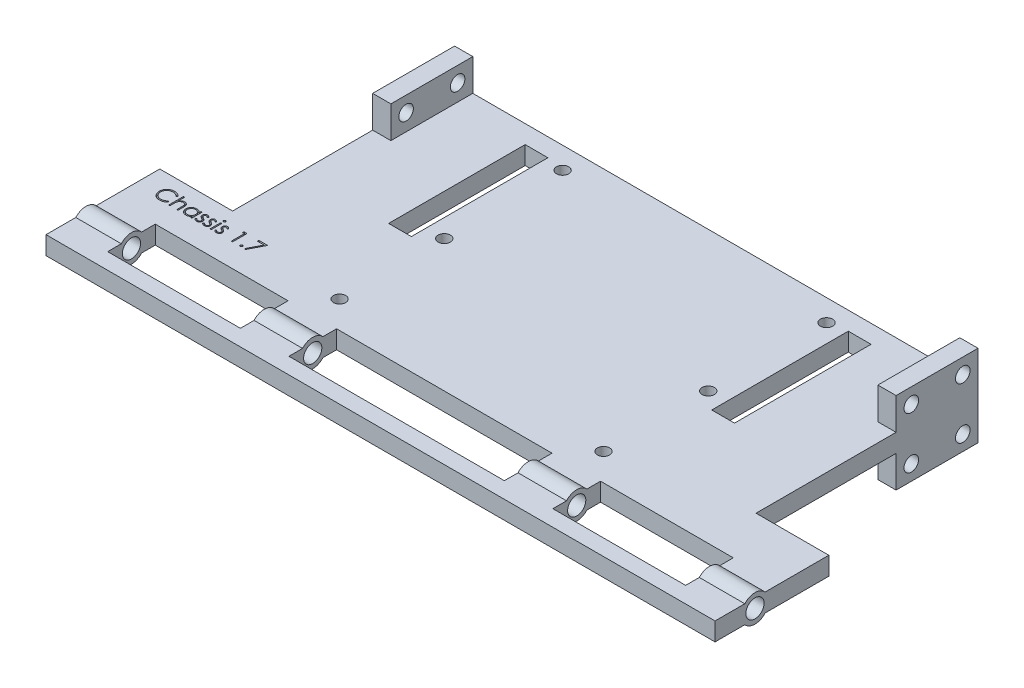
from build123d import *

# Parameters (mm, degrees)
SKETCH1_R           = 1.35
SKETCH1_W           = 5
SKETCH1_H           = 30
BASE_CHASSIS_DEPTH  = 2
SKETCH14_W          = 0.284935898
SKETCH14_H          = 2.320192307
TEXT_2_DEPTH        = 0.5
SKETCH7_W           = 18
SKETCH7_H           = 18
SKETCH7_R           = 1.6
MOUNT_HOLES_DEPTH   = 4
SKETCH8_R           = 3
SHAFT_EXTRUDE_DEPTH = 147
SKETCH20_R          = 2
SHAFT_CUT_DEPTH     = 148.0000001
SCREW_START         = -12
SCREW_HOLE_DEPTH    = 20


with BuildPart() as part:
    # Sketch1 → Base Chassis (new body, symmetric)
    with BuildSketch(Plane(origin=(0, 0, 0), x_dir=(1, 0, 0), z_dir=(0, 1, 0))):
        Polygon((0, 0), (115, 0), (115, -48.77649394), (131, -48.77649394), (131, -73.77649394), (-16, -73.77649394), (-16, -48.77649394), (0, -48.77649394), align=None)
        with Locations((28.5, -30.77649394)):
            Circle(SKETCH1_R, mode=Mode.SUBTRACT)
        with Locations((28.5, -53.77649394)):
            Circle(SKETCH1_R, mode=Mode.SUBTRACT)
        with Locations((86.5, -30.77649394)):
            Circle(SKETCH1_R, mode=Mode.SUBTRACT)
        with Locations((86.5, -53.77649394)):
            Circle(SKETCH1_R, mode=Mode.SUBTRACT)
        with Locations((86.5, -4.77649394)):
            Circle(SKETCH1_R, mode=Mode.SUBTRACT)
        with Locations((28.5, -4.77649394)):
            Circle(SKETCH1_R, mode=Mode.SUBTRACT)
        with Locations((22, -19)):
            Rectangle(SKETCH1_W, SKETCH1_H, mode=Mode.SUBTRACT)
        with Locations((93, -19)):
            Rectangle(SKETCH1_W, SKETCH1_H, mode=Mode.SUBTRACT)
    extrude(amount=BASE_CHASSIS_DEPTH, both=True)

    # Sketch14 → Text 2 (cut)
    with BuildSketch(Plane(origin=(0, 2, 0), x_dir=(1, 0, 0), z_dir=(0, 1, 0))):
        with BuildLine():
            Line((-8.734459633, -52.056852352), (-8.983778544, -52.24765764))
            add(Edge.make_bspline(
                [(-8.983778544, -52.24765764), (-9.001563885, -52.226461368), (-9.036894783, -52.184354594), (-9.093735631, -52.125227436), (-9.15297355, -52.06983252), (-9.214585896, -52.017905958), (-9.279681669, -51.971263606), (-9.346683965, -51.92747482), (-9.41671362, -51.8882248), (-9.513552693, -51.840633377), (-9.640233241, -51.790970794), (-9.799704274, -51.749330005), (-9.966175056, -51.722822225), (-10.079747165, -51.719951261), (-10.137514521, -51.718490974)],
                knots=[0, 0, 0, 0, 8.299e-05, 0.000164861, 0.000245858, 0.000326233, 0.000406381, 0.000485944, 0.000566254, 0.000647036, 0.000809554, 0.000973391, 0.001140702, 0.001313896, 0.001313896, 0.001313896, 0.001313896], degree=3))
            add(Edge.make_bspline(
                [(-10.137514521, -51.718490974), (-10.169340086, -51.718857425), (-10.232695843, -51.719586928), (-10.326719815, -51.72921092), (-10.418988083, -51.742737517), (-10.509440628, -51.762808346), (-10.597962311, -51.788183508), (-10.685131848, -51.818505134), (-10.769687177, -51.856019881), (-10.852798008, -51.897483803), (-10.932426292, -51.94431727), (-11.007769085, -51.995401525), (-11.078551599, -52.05016492), (-11.144829826, -52.108812709), (-11.206671522, -52.171080773), (-11.263628582, -52.237632712), (-11.315503919, -52.308255755), (-11.363325792, -52.382018632), (-11.406154485, -52.458706486), (-11.442013733, -52.538603157), (-11.47376838, -52.62034045), (-11.49889555, -52.70484186), (-11.518784219, -52.791512798), (-11.53250717, -52.88058587), (-11.542021712, -52.971874993), (-11.542747587, -53.033750584), (-11.543113479, -53.064940292)],
                knots=[0, 0, 0, 0, 9.5437e-05, 0.000189987, 0.000283265, 0.000375086, 0.000467691, 0.000559419, 0.000651703, 0.000744998, 0.000837935, 0.000928607, 0.001017915, 0.001106228, 0.001193927, 0.001280987, 0.00136876, 0.001456615, 0.001544584, 0.001631962, 0.001719133, 0.001807466, 0.001896183, 0.00198569, 0.002077709, 0.002171238, 0.002171238, 0.002171238, 0.002171238], degree=3))
            add(Edge.make_bspline(
                [(-11.543113479, -53.064940292), (-11.541968829, -53.11186799), (-11.539721461, -53.204004299), (-11.519720472, -53.338960496), (-11.489326568, -53.468247107), (-11.443773866, -53.591055964), (-11.387604441, -53.708901403), (-11.316629029, -53.819789506), (-11.234426885, -53.925395961), (-11.13983509, -54.02322492), (-11.036052671, -54.112590943), (-10.92470278, -54.191286113), (-10.806062748, -54.256886042), (-10.681442519, -54.311474222), (-10.549883115, -54.353435682), (-10.411621116, -54.382975994), (-10.266957235, -54.402245687), (-10.168106422, -54.404090532), (-10.117797975, -54.405029435)],
                knots=[0, 0, 0, 0, 0.000140704, 0.000276253, 0.000408455, 0.000538433, 0.000668431, 0.000799358, 0.000932567, 0.001069312, 0.00120687, 0.001342915, 0.001477586, 0.00161288, 0.00175046, 0.001891054, 0.002036604, 0.002187448, 0.002187448, 0.002187448, 0.002187448], degree=3))
            add(Edge.make_bspline(
                [(-10.117797975, -54.405029435), (-10.062369107, -54.403497471), (-9.953271835, -54.400482198), (-9.79328084, -54.374937736), (-9.640122681, -54.333519482), (-9.49378912, -54.275554938), (-9.354692691, -54.200202856), (-9.222615721, -54.108855496), (-9.097446725, -54.000643937), (-9.022179919, -53.918018527), (-8.983778544, -53.875862768)],
                knots=[0, 0, 0, 0, 0.000166206, 0.000327134, 0.000484664, 0.00064139, 0.000798189, 0.000958205, 0.001122325, 0.001293282, 0.001293282, 0.001293282, 0.001293282], degree=3))
            Line((-8.983778544, -53.875862768), (-8.734459633, -54.064760004))
            add(Edge.make_bspline(
                [(-8.734459633, -54.064760004), (-8.754523919, -54.090648457), (-8.794556383, -54.142301358), (-8.859379012, -54.215119266), (-8.927666275, -54.283612213), (-8.999925383, -54.347227984), (-9.075325094, -54.407239534), (-9.155219263, -54.46194191), (-9.2385576, -54.512098641), (-9.325057734, -54.558024494), (-9.414627762, -54.598770853), (-9.507160356, -54.633653914), (-9.602256664, -54.663702921), (-9.699921032, -54.688424321), (-9.80035604, -54.707720233), (-9.903199256, -54.720619509), (-10.008672643, -54.729456817), (-10.079830218, -54.730262284), (-10.115889922, -54.730670461)],
                knots=[0, 0, 0, 0, 9.8237e-05, 0.000196004, 0.000292247, 0.000388218, 0.000484669, 0.00058117, 0.000678466, 0.000776338, 0.000874822, 0.000973456, 0.001072826, 0.001173865, 0.001275526, 0.001379423, 0.001484691, 0.001592844, 0.001592844, 0.001592844, 0.001592844], degree=3))
            add(Edge.make_bspline(
                [(-10.115889922, -54.730670461), (-10.150038105, -54.730432796), (-10.21756191, -54.729962844), (-10.317255778, -54.722349949), (-10.414310612, -54.711963402), (-10.508449022, -54.69632414), (-10.600184728, -54.677868917), (-10.688686115, -54.653129992), (-10.774824056, -54.625417533), (-10.85825248, -54.592846581), (-10.93904235, -54.556092616), (-11.016933093, -54.51455313), (-11.091888886, -54.468577438), (-11.16464666, -54.419178965), (-11.234131611, -54.364770984), (-11.300945881, -54.306109108), (-11.365464127, -54.243391056), (-11.405380848, -54.198165581), (-11.425450218, -54.175427071)],
                knots=[0, 0, 0, 0, 0.000102417, 0.000202516, 0.000299794, 0.000395154, 0.000488707, 0.000580357, 0.000670665, 0.000760075, 0.000848874, 0.000936794, 0.001024712, 0.001112565, 0.001200478, 0.001289268, 0.001379219, 0.001470177, 0.001470177, 0.001470177, 0.001470177], degree=3))
            add(Edge.make_bspline(
                [(-11.425450218, -54.175427071), (-11.457595409, -54.135928993), (-11.521497706, -54.057409691), (-11.603254576, -53.930150265), (-11.67323843, -53.797282676), (-11.729822301, -53.658108883), (-11.774057066, -53.512941182), (-11.804701436, -53.361706394), (-11.824614677, -53.204545761), (-11.826891867, -53.09765096), (-11.828049377, -53.043315693)],
                knots=[0, 0, 0, 0, 0.000152677, 0.000303511, 0.000452867, 0.000602629, 0.000753527, 0.000907451, 0.001065071, 0.001228016, 0.001228016, 0.001228016, 0.001228016], degree=3))
            add(Edge.make_bspline(
                [(-11.828049377, -53.043315693), (-11.826638594, -52.986206103), (-11.823862967, -52.87384655), (-11.800281067, -52.708951607), (-11.762345445, -52.550971409), (-11.708463982, -52.40020087), (-11.64015127, -52.255846972), (-11.555762842, -52.119012451), (-11.456279077, -51.988822211), (-11.342480212, -51.867251687), (-11.217686986, -51.756090988), (-11.084047777, -51.658295361), (-10.941824153, -51.576908757), (-10.792582959, -51.508876524), (-10.635206663, -51.456584761), (-10.470031035, -51.419978656), (-10.297366448, -51.397193843), (-10.179562676, -51.394313476), (-10.119706028, -51.392849948)],
                knots=[0, 0, 0, 0, 0.000171259, 0.000336941, 0.000498606, 0.000657931, 0.000816392, 0.000976852, 0.001139297, 0.001307149, 0.001475639, 0.001640004, 0.001802988, 0.001966374, 0.002131298, 0.002299486, 0.002473278, 0.002652798, 0.002652798, 0.002652798, 0.002652798], degree=3))
            add(Edge.make_bspline(
                [(-10.119706028, -51.392849948), (-10.083225757, -51.393287316), (-10.011016734, -51.394153042), (-9.904198256, -51.402595043), (-9.800201288, -51.4166681), (-9.698954183, -51.435823392), (-9.599964381, -51.459597176), (-9.503988449, -51.490567304), (-9.410463211, -51.525979015), (-9.319978516, -51.566762766), (-9.232968503, -51.61254331), (-9.149460271, -51.662813197), (-9.070117149, -51.717510106), (-8.994380837, -51.776168844), (-8.923518274, -51.840030394), (-8.855517504, -51.907338213), (-8.792687812, -51.980031039), (-8.753904556, -52.031198372), (-8.734459633, -52.056852352)],
                knots=[0, 0, 0, 0, 0.000109425, 0.000216595, 0.000321206, 0.000424117, 0.000525619, 0.000626393, 0.000726442, 0.000825506, 0.000923941, 0.001021237, 0.001117738, 0.001212903, 0.001308399, 0.001403742, 0.001499772, 0.001596332, 0.001596332, 0.001596332, 0.001596332], degree=3))
        make_face()
        with BuildLine():
            Line((-8.164587838, -51.392849948), (-7.879651941, -51.392849948))
            Line((-7.879651941, -51.392849948), (-7.879651941, -52.767284042))
            add(Edge.make_bspline(
                [(-7.879651941, -52.767284042), (-7.849065532, -52.72905343), (-7.789512225, -52.654616469), (-7.689276462, -52.557496674), (-7.586342171, -52.473315068), (-7.477154094, -52.40630401), (-7.363715407, -52.353366289), (-7.245547673, -52.315821781), (-7.122628935, -52.292734001), (-7.039148977, -52.289832579), (-6.996859473, -52.288362768)],
                knots=[0, 0, 0, 0, 0.000146744, 0.000285718, 0.000417826, 0.00054491, 0.000668979, 0.000792481, 0.000915983, 0.001042781, 0.001042781, 0.001042781, 0.001042781], degree=3))
            add(Edge.make_bspline(
                [(-6.996859473, -52.288362768), (-6.953924045, -52.289946123), (-6.869889057, -52.29304513), (-6.747532301, -52.317550126), (-6.633267793, -52.359421516), (-6.527435207, -52.416723031), (-6.432344232, -52.488090525), (-6.348116232, -52.570487692), (-6.279317793, -52.665986175), (-6.232510022, -52.754211491), (-6.202054145, -52.832714503), (-6.182775703, -52.900057625), (-6.166429716, -52.975098218), (-6.152187812, -53.057797654), (-6.142695849, -53.148552916), (-6.13507166, -53.246954561), (-6.129650162, -53.352996947), (-6.129440064, -53.426403173), (-6.129331428, -53.464359363)],
                knots=[0, 0, 0, 0, 0.000128741, 0.000251978, 0.000372501, 0.000492599, 0.000611662, 0.000728143, 0.000844672, 0.000963309, 0.001026736, 0.001096978, 0.001173207, 0.001257065, 0.001348583, 0.001446826, 0.001553163, 0.001667017, 0.001667017, 0.001667017, 0.001667017], degree=3))
            Line((-6.129331428, -53.464359363), (-6.129331428, -54.649260204))
            Line((-6.129331428, -54.649260204), (-6.414267326, -54.649260204))
            Line((-6.414267326, -54.649260204), (-6.414267326, -53.557853954))
            add(Edge.make_bspline(
                [(-6.414267326, -53.557853954), (-6.414439958, -53.526264818), (-6.414770174, -53.465840177), (-6.415861779, -53.379329493), (-6.41829856, -53.300865143), (-6.422236309, -53.230698594), (-6.426377695, -53.168732025), (-6.432077562, -53.115055426), (-6.438708988, -53.069595072), (-6.444667811, -53.042231445), (-6.447340242, -53.029959323)],
                knots=[0, 0, 0, 0, 9.4769e-05, 0.000181277, 0.000259548, 0.000330249, 0.000392103, 0.000445834, 0.000492159, 0.000529829, 0.000529829, 0.000529829, 0.000529829], degree=3))
            add(Edge.make_bspline(
                [(-6.447340242, -53.029959323), (-6.457703665, -52.993950955), (-6.477627284, -52.924725078), (-6.523935092, -52.830688463), (-6.581773623, -52.750510877), (-6.65239221, -52.685274344), (-6.734541583, -52.634101019), (-6.828757408, -52.598660959), (-6.934152956, -52.576664812), (-7.008403934, -52.574452015), (-7.047104866, -52.573298666)],
                knots=[0, 0, 0, 0, 0.000112235, 0.000215771, 0.000312707, 0.000407219, 0.000502346, 0.000601207, 0.000707732, 0.000823699, 0.000823699, 0.000823699, 0.000823699], degree=3))
            add(Edge.make_bspline(
                [(-7.047104866, -52.573298666), (-7.070026346, -52.573730308), (-7.115387362, -52.574584518), (-7.182650795, -52.583160554), (-7.247900731, -52.597174749), (-7.311765564, -52.616138152), (-7.37289175, -52.641942317), (-7.433061016, -52.671814703), (-7.49056862, -52.708380049), (-7.546435754, -52.749406281), (-7.598430945, -52.794826705), (-7.646806257, -52.842766443), (-7.689930323, -52.893815875), (-7.728999687, -52.94715598), (-7.762725704, -53.003518393), (-7.792165285, -53.062359596), (-7.817144096, -53.123756971), (-7.829556252, -53.166370063), (-7.835766725, -53.187691695)],
                knots=[0, 0, 0, 0, 6.8737e-05, 0.000136029, 0.000203016, 0.000268809, 0.000335543, 0.000401817, 0.000470111, 0.000539693, 0.000609577, 0.000677037, 0.000743816, 0.000809842, 0.000875179, 0.000940599, 0.001007093, 0.001073681, 0.001073681, 0.001073681, 0.001073681], degree=3))
            add(Edge.make_bspline(
                [(-7.835766725, -53.187691695), (-7.839340348, -53.203132129), (-7.847127713, -53.236778735), (-7.855577597, -53.292272586), (-7.86314117, -53.356758081), (-7.869535212, -53.430137411), (-7.873456869, -53.512679466), (-7.877682558, -53.603820979), (-7.879255557, -53.704132855), (-7.879515864, -53.773888066), (-7.879651941, -53.810352953)],
                knots=[0, 0, 0, 0, 4.7531e-05, 0.000103577, 0.000168266, 0.000242318, 0.000324485, 0.000416151, 0.000516024, 0.000625421, 0.000625421, 0.000625421, 0.000625421], degree=3))
            Line((-7.879651941, -53.810352953), (-7.879651941, -54.649260204))
            Line((-7.879651941, -54.649260204), (-8.164587838, -54.649260204))
            Line((-8.164587838, -54.649260204), (-8.164587838, -51.392849948))
        make_face()
        with BuildLine():
            Line((-3.117151941, -52.329067897), (-3.117151941, -54.649260204))
            Line((-3.117151941, -54.649260204), (-3.402087838, -54.649260204))
            Line((-3.402087838, -54.649260204), (-3.402087838, -54.247933081))
            add(Edge.make_bspline(
                [(-3.402087838, -54.247933081), (-3.434217741, -54.284254713), (-3.496919651, -54.355136834), (-3.601641237, -54.447739947), (-3.712646655, -54.524283139), (-3.829397139, -54.586104848), (-3.95178726, -54.632543356), (-4.079545711, -54.665550801), (-4.212724606, -54.686772351), (-4.303667814, -54.688891457), (-4.349754104, -54.689965333)],
                knots=[0, 0, 0, 0, 0.000145381, 0.000283713, 0.000418146, 0.000549018, 0.000679067, 0.000809885, 0.000944361, 0.001082524, 0.001082524, 0.001082524, 0.001082524], degree=3))
            add(Edge.make_bspline(
                [(-4.349754104, -54.689965333), (-4.390727891, -54.688852838), (-4.471530013, -54.686658949), (-4.590392104, -54.669638859), (-4.704775788, -54.642306081), (-4.81478915, -54.604295988), (-4.91972031, -54.553876243), (-5.020467684, -54.493513825), (-5.11650934, -54.421631072), (-5.206381379, -54.339454789), (-5.289141837, -54.250196479), (-5.361768848, -54.154995876), (-5.422323428, -54.054264643), (-5.472960215, -53.949278139), (-5.511964042, -53.839228177), (-5.53915441, -53.724495317), (-5.556154673, -53.605215217), (-5.558347655, -53.523990079), (-5.559459633, -53.482803874)],
                knots=[0, 0, 0, 0, 0.000122885, 0.000242334, 0.00035942, 0.00047528, 0.000590784, 0.00070804, 0.000827103, 0.000950019, 0.001072896, 0.001191833, 0.001308545, 0.001424896, 0.001540967, 0.001658053, 0.001778133, 0.001901653, 0.001901653, 0.001901653, 0.001901653], degree=3))
            add(Edge.make_bspline(
                [(-5.559459633, -53.482803874), (-5.558323009, -53.442468943), (-5.556075965, -53.36272896), (-5.539336258, -53.245454713), (-5.5111867, -53.132498862), (-5.471682581, -53.024225063), (-5.421025951, -52.920502304), (-5.359405472, -52.821257224), (-5.286816695, -52.726216413), (-5.203130582, -52.637614658), (-5.11247547, -52.555771672), (-5.015493978, -52.484643466), (-4.914598573, -52.423214611), (-4.80822427, -52.374543243), (-4.69794554, -52.335164984), (-4.582780628, -52.307920791), (-4.463208696, -52.291866793), (-4.382028035, -52.289541999), (-4.340849858, -52.288362768)],
                knots=[0, 0, 0, 0, 0.000120979, 0.000239169, 0.000354553, 0.000469642, 0.000584275, 0.000700235, 0.000819557, 0.000942401, 0.001065363, 0.001185447, 0.001302704, 0.001419089, 0.001535759, 0.001653464, 0.001773457, 0.001896977, 0.001896977, 0.001896977, 0.001896977], degree=3))
            add(Edge.make_bspline(
                [(-4.340849858, -52.288362768), (-4.293497128, -52.289667014), (-4.200640661, -52.292224579), (-4.064815967, -52.313508625), (-3.936324191, -52.349466377), (-3.814173457, -52.39837725), (-3.698802406, -52.463372883), (-3.59130327, -52.545360419), (-3.49055101, -52.643822782), (-3.432148889, -52.719451685), (-3.402087838, -52.758379796)],
                knots=[0, 0, 0, 0, 0.000142004, 0.000278464, 0.000411172, 0.000541562, 0.000672282, 0.000807119, 0.000946093, 0.001093501, 0.001093501, 0.001093501, 0.001093501], degree=3))
            Line((-3.402087838, -52.758379796), (-3.402087838, -52.329067897))
            Line((-3.402087838, -52.329067897), (-3.117151941, -52.329067897))
        make_face()
        with BuildLine():
            add(Edge.make_bspline(
                [(-4.337033752, -52.573298666), (-4.378684616, -52.574780609), (-4.460896796, -52.577705728), (-4.581586712, -52.600541684), (-4.697078166, -52.638536995), (-4.806793533, -52.690499862), (-4.908999701, -52.755840216), (-5.000343245, -52.834871757), (-5.081571267, -52.925438191), (-5.149886621, -53.02713082), (-5.205576572, -53.136149517), (-5.244735237, -53.250108829), (-5.270560911, -53.366953344), (-5.273199355, -53.44620378), (-5.274523736, -53.485983962)],
                knots=[0, 0, 0, 0, 0.000124893, 0.000246519, 0.000366995, 0.00048876, 0.000609786, 0.000729752, 0.00085002, 0.00097368, 0.001096273, 0.001216155, 0.001334406, 0.001453586, 0.001453586, 0.001453586, 0.001453586], degree=3))
            add(Edge.make_bspline(
                [(-5.274523736, -53.485983962), (-5.272832011, -53.525526417), (-5.269455193, -53.604456332), (-5.245188492, -53.721460141), (-5.204476035, -53.835446308), (-5.148920735, -53.945447352), (-5.079355011, -54.047577215), (-4.998720305, -54.13987004), (-4.906236836, -54.219235595), (-4.803795454, -54.285672537), (-4.694386795, -54.339341395), (-4.5793303, -54.376684511), (-4.460788829, -54.400794355), (-4.380187069, -54.403610559), (-4.339577822, -54.405029435)],
                knots=[0, 0, 0, 0, 0.000118588, 0.000236711, 0.000356804, 0.000480819, 0.000605362, 0.000726581, 0.000847444, 0.000969696, 0.001092011, 0.001211883, 0.001331754, 0.001453472, 0.001453472, 0.001453472, 0.001453472], degree=3))
            add(Edge.make_bspline(
                [(-4.339577822, -54.405029435), (-4.298351352, -54.403523611), (-4.216355991, -54.400528675), (-4.095308021, -54.377594956), (-3.97783759, -54.339704689), (-3.86554489, -54.28718191), (-3.760936685, -54.222087737), (-3.667049325, -54.145881304), (-3.587659839, -54.057250559), (-3.520356544, -53.959844776), (-3.46758313, -53.853063179), (-3.42914199, -53.739367164), (-3.406414519, -53.618752771), (-3.403550007, -53.536326208), (-3.402087838, -53.494252192)],
                knots=[0, 0, 0, 0, 0.000123623, 0.000245874, 0.000368165, 0.000493079, 0.000616791, 0.00073699, 0.000854515, 0.000972537, 0.001091147, 0.001210617, 0.001331618, 0.00145778, 0.00145778, 0.00145778, 0.00145778], degree=3))
            add(Edge.make_bspline(
                [(-3.402087838, -53.494252192), (-3.402958384, -53.462195731), (-3.404671893, -53.399098472), (-3.417762481, -53.306454224), (-3.438585878, -53.217795773), (-3.467928475, -53.133029905), (-3.506474141, -53.052625284), (-3.552963185, -52.976004587), (-3.608213129, -52.903566316), (-3.671334575, -52.836307959), (-3.740427294, -52.774961097), (-3.813538056, -52.720202107), (-3.891533062, -52.675218006), (-3.97310066, -52.63798771), (-4.058382371, -52.608361195), (-4.148072147, -52.588596645), (-4.241216657, -52.575025496), (-4.304758436, -52.573880337), (-4.337033752, -52.573298666)],
                knots=[0, 0, 0, 0, 9.6142e-05, 0.000189237, 0.000280101, 0.000369007, 0.000457768, 0.000547103, 0.000637419, 0.000730567, 0.000823369, 0.000914322, 0.0010041, 0.001092899, 0.001183007, 0.001274346, 0.001368072, 0.001464822, 0.001464822, 0.001464822, 0.001464822], degree=3))
        make_face(mode=Mode.SUBTRACT)
        with BuildLine():
            Line((-1.366831428, -52.618455917), (-1.560180787, -52.817529435))
            add(Edge.make_bspline(
                [(-1.560180787, -52.817529435), (-1.576863601, -52.798195367), (-1.609026102, -52.760921559), (-1.660036089, -52.711085791), (-1.7108575, -52.669232997), (-1.760794638, -52.633897733), (-1.811103211, -52.60718315), (-1.861192844, -52.58768424), (-1.9111154, -52.575617602), (-1.944485589, -52.574062361), (-1.960871893, -52.573298666)],
                knots=[0, 0, 0, 0, 7.6587e-05, 0.00014765, 0.000213612, 0.00027395, 0.000330855, 0.000384007, 0.00043492, 0.000484042, 0.000484042, 0.000484042, 0.000484042], degree=3))
            add(Edge.make_bspline(
                [(-1.960871893, -52.573298666), (-1.980955482, -52.574273729), (-2.020477144, -52.576192516), (-2.077106279, -52.595345413), (-2.129675775, -52.624744769), (-2.175175321, -52.666444841), (-2.213717716, -52.714309571), (-2.241851555, -52.767827666), (-2.259056412, -52.825384105), (-2.261237847, -52.865325476), (-2.262344249, -52.885583321)],
                knots=[0, 0, 0, 0, 6.0059e-05, 0.000118188, 0.000177433, 0.0002396, 0.000302079, 0.000360968, 0.00041994, 0.000480632, 0.000480632, 0.000480632, 0.000480632], degree=3))
            add(Edge.make_bspline(
                [(-2.262344249, -52.885583321), (-2.261336583, -52.903918533), (-2.259324093, -52.940537269), (-2.243678891, -52.994555843), (-2.21876324, -53.04722187), (-2.195476707, -53.079482507), (-2.183478063, -53.096105156)],
                knots=[0, 0, 0, 0, 5.4934e-05, 0.000109712, 0.000167464, 0.000228852, 0.000228852, 0.000228852, 0.000228852], degree=3))
            add(Edge.make_bspline(
                [(-2.183478063, -53.096105156), (-2.176254036, -53.104981172), (-2.160878606, -53.123872653), (-2.132023739, -53.150092577), (-2.099346183, -53.179068762), (-2.060048811, -53.208040035), (-2.015824664, -53.238548815), (-1.965714742, -53.269393607), (-1.911309298, -53.302925621), (-1.872359027, -53.324193073), (-1.852112878, -53.335247784)],
                knots=[0, 0, 0, 0, 3.4286e-05, 7.2973e-05, 0.000116711, 0.000165303, 0.000219286, 0.000277872, 0.000341791, 0.00041098, 0.00041098, 0.00041098, 0.00041098], degree=3))
            add(Edge.make_bspline(
                [(-1.852112878, -53.335247784), (-1.827426276, -53.349077089), (-1.77973989, -53.375790752), (-1.71198288, -53.417255983), (-1.65049035, -53.458468775), (-1.59474128, -53.498988374), (-1.545808353, -53.539948475), (-1.502206938, -53.579779083), (-1.465024563, -53.61968367), (-1.444202073, -53.647562994), (-1.434249297, -53.66088881)],
                knots=[0, 0, 0, 0, 8.4884e-05, 0.000163968, 0.000238232, 0.000306925, 0.000370606, 0.000429564, 0.000484028, 0.000533898, 0.000533898, 0.000533898, 0.000533898], degree=3))
            add(Edge.make_bspline(
                [(-1.434249297, -53.66088881), (-1.417729747, -53.68780019), (-1.384852777, -53.741358831), (-1.350328492, -53.829549833), (-1.330316671, -53.923085788), (-1.3275388, -53.987068588), (-1.3261263, -54.019602752)],
                knots=[0, 0, 0, 0, 9.4587e-05, 0.000188246, 0.000282553, 0.000380115, 0.000380115, 0.000380115, 0.000380115], degree=3))
            add(Edge.make_bspline(
                [(-1.3261263, -54.019602752), (-1.32677902, -54.042525478), (-1.328065276, -54.087697213), (-1.337007951, -54.15422238), (-1.352388537, -54.217844443), (-1.373337871, -54.279253737), (-1.401626552, -54.337273632), (-1.434780625, -54.393367943), (-1.474581438, -54.446323252), (-1.520021471, -54.496070023), (-1.569774169, -54.541504951), (-1.622847595, -54.581440966), (-1.679307105, -54.614619115), (-1.738749275, -54.642074107), (-1.801309161, -54.663907455), (-1.866996545, -54.679022751), (-1.93560263, -54.68806947), (-1.982256813, -54.689325388), (-2.006029145, -54.689965333)],
                knots=[0, 0, 0, 0, 6.8763e-05, 0.000135506, 0.000200914, 0.000264877, 0.000329738, 0.000394202, 0.000460094, 0.000528077, 0.000596059, 0.000661951, 0.000726961, 0.000792128, 0.000858102, 0.000925367, 0.000994001, 0.001065306, 0.001065306, 0.001065306, 0.001065306], degree=3))
            add(Edge.make_bspline(
                [(-2.006029145, -54.689965333), (-2.038112225, -54.689064812), (-2.101832595, -54.687276282), (-2.196075411, -54.670488641), (-2.288169242, -54.644367105), (-2.377417168, -54.608339079), (-2.461823286, -54.562845218), (-2.539049196, -54.508360047), (-2.609363165, -54.446683406), (-2.649384742, -54.399409552), (-2.669395531, -54.375772624)],
                knots=[0, 0, 0, 0, 9.6173e-05, 0.00019101, 0.000286237, 0.000382966, 0.000479156, 0.000573205, 0.000666007, 0.000758809, 0.000758809, 0.000758809, 0.000758809], degree=3))
            Line((-2.669395531, -54.375772624), (-2.480498295, -54.160798666))
            add(Edge.make_bspline(
                [(-2.480498295, -54.160798666), (-2.462561892, -54.180170488), (-2.427789462, -54.217725694), (-2.372180501, -54.267731346), (-2.315593473, -54.309642499), (-2.258593436, -54.344697597), (-2.200336636, -54.371708141), (-2.141149543, -54.390684294), (-2.081152544, -54.402880097), (-2.040855321, -54.404311825), (-2.02065755, -54.405029435)],
                knots=[0, 0, 0, 0, 7.9173e-05, 0.000153489, 0.000223961, 0.000290171, 0.000353916, 0.000416067, 0.000476314, 0.000536856, 0.000536856, 0.000536856, 0.000536856], degree=3))
            add(Edge.make_bspline(
                [(-2.02065755, -54.405029435), (-1.99315486, -54.403785901), (-1.939419217, -54.401356244), (-1.862453808, -54.379297168), (-1.791389482, -54.344707855), (-1.72968259, -54.295645307), (-1.677157058, -54.238535609), (-1.639122214, -54.174206372), (-1.61528597, -54.104545551), (-1.612486528, -54.056256248), (-1.611062197, -54.031687087)],
                knots=[0, 0, 0, 0, 8.2344e-05, 0.000160886, 0.000238253, 0.000318022, 0.000395931, 0.000469778, 0.000540776, 0.000614315, 0.000614315, 0.000614315, 0.000614315], degree=3))
            add(Edge.make_bspline(
                [(-1.611062197, -54.031687087), (-1.612047622, -54.011449076), (-1.61399321, -53.971491832), (-1.629272464, -53.913661166), (-1.653414122, -53.85880689), (-1.677185482, -53.826703424), (-1.689292366, -53.810352953)],
                knots=[0, 0, 0, 0, 6.0636e-05, 0.000119717, 0.000178355, 0.000239217, 0.000239217, 0.000239217, 0.000239217], degree=3))
            add(Edge.make_bspline(
                [(-1.689292366, -53.810352953), (-1.696569823, -53.802156588), (-1.712422755, -53.784301947), (-1.741501438, -53.75851634), (-1.77631927, -53.730723207), (-1.817267847, -53.701393837), (-1.864429716, -53.670915102), (-1.917996025, -53.639446904), (-1.977232955, -53.60549461), (-2.019116314, -53.582979637), (-2.041010114, -53.571210325)],
                knots=[0, 0, 0, 0, 3.2858e-05, 7.1577e-05, 0.000116374, 0.000166503, 0.000222602, 0.000284776, 0.000352857, 0.000427423, 0.000427423, 0.000427423, 0.000427423], degree=3))
            add(Edge.make_bspline(
                [(-2.041010114, -53.571210325), (-2.064638138, -53.558021255), (-2.110460416, -53.53244344), (-2.17536403, -53.492605282), (-2.233917701, -53.452085683), (-2.287530365, -53.413157607), (-2.334847849, -53.373768608), (-2.375683745, -53.333874958), (-2.411645805, -53.295085542), (-2.431555242, -53.267601566), (-2.441065202, -53.254473546)],
                knots=[0, 0, 0, 0, 8.1176e-05, 0.000157427, 0.000228345, 0.000294747, 0.000356148, 0.000412822, 0.000465959, 0.000514551, 0.000514551, 0.000514551, 0.000514551], degree=3))
            add(Edge.make_bspline(
                [(-2.441065202, -53.254473546), (-2.457512246, -53.228034309), (-2.490412082, -53.175146597), (-2.522357291, -53.086872093), (-2.544315617, -52.993939791), (-2.546277214, -52.929816716), (-2.547280146, -52.897031639)],
                knots=[0, 0, 0, 0, 9.3167e-05, 0.000186367, 0.000280188, 0.000378341, 0.000378341, 0.000378341, 0.000378341], degree=3))
            add(Edge.make_bspline(
                [(-2.547280146, -52.897031639), (-2.546795555, -52.875600028), (-2.54584714, -52.833655329), (-2.538277894, -52.772025113), (-2.524496841, -52.713470716), (-2.507211304, -52.657112776), (-2.483187436, -52.60404302), (-2.454480079, -52.553553742), (-2.420745772, -52.505714731), (-2.381880787, -52.46126189), (-2.33914833, -52.420885572), (-2.292979504, -52.385689674), (-2.244412657, -52.355657481), (-2.193242162, -52.330470514), (-2.138976447, -52.311419259), (-2.081994825, -52.298304346), (-2.022412635, -52.289545698), (-1.981680899, -52.288762757), (-1.960871893, -52.288362768)],
                knots=[0, 0, 0, 0, 6.4288e-05, 0.000125821, 0.00018584, 0.000244574, 0.000302371, 0.000360196, 0.000418606, 0.00047766, 0.000537052, 0.000594677, 0.000651511, 0.000708117, 0.000765447, 0.000823607, 0.000883331, 0.000945713, 0.000945713, 0.000945713, 0.000945713], degree=3))
            add(Edge.make_bspline(
                [(-1.960871893, -52.288362768), (-1.936204807, -52.289364563), (-1.886407906, -52.291386945), (-1.811700495, -52.307448536), (-1.737103106, -52.333876423), (-1.662424067, -52.370376435), (-1.588210447, -52.41760853), (-1.513809442, -52.474694394), (-1.438327871, -52.541258464), (-1.391196073, -52.592148475), (-1.366831428, -52.618455917)],
                knots=[0, 0, 0, 0, 7.3953e-05, 0.000149294, 0.000228145, 0.00031092, 0.000398091, 0.000491588, 0.000592049, 0.000699558, 0.000699558, 0.000699558, 0.000699558], degree=3))
        make_face()
        with BuildLine():
            Line((0.342783956, -52.618455917), (0.149434597, -52.817529435))
            add(Edge.make_bspline(
                [(0.149434597, -52.817529435), (0.132751784, -52.798195367), (0.100589282, -52.760921559), (0.049579296, -52.711085791), (-0.001242116, -52.669232997), (-0.051179254, -52.633897733), (-0.101487827, -52.60718315), (-0.151577459, -52.58768424), (-0.201500015, -52.575617602), (-0.234870204, -52.574062361), (-0.251256508, -52.573298666)],
                knots=[0, 0, 0, 0, 7.6587e-05, 0.00014765, 0.000213612, 0.00027395, 0.000330855, 0.000384007, 0.00043492, 0.000484042, 0.000484042, 0.000484042, 0.000484042], degree=3))
            add(Edge.make_bspline(
                [(-0.251256508, -52.573298666), (-0.271340098, -52.574273729), (-0.310861759, -52.576192516), (-0.367490894, -52.595345413), (-0.42006039, -52.624744769), (-0.465559936, -52.666444841), (-0.504102332, -52.714309571), (-0.532236171, -52.767827666), (-0.549441027, -52.825384105), (-0.551622463, -52.865325476), (-0.552728864, -52.885583321)],
                knots=[0, 0, 0, 0, 6.0059e-05, 0.000118188, 0.000177433, 0.0002396, 0.000302079, 0.000360968, 0.00041994, 0.000480632, 0.000480632, 0.000480632, 0.000480632], degree=3))
            add(Edge.make_bspline(
                [(-0.552728864, -52.885583321), (-0.551721199, -52.903918533), (-0.549708708, -52.940537269), (-0.534063507, -52.994555843), (-0.509147855, -53.04722187), (-0.485861322, -53.079482507), (-0.473862678, -53.096105156)],
                knots=[0, 0, 0, 0, 5.4934e-05, 0.000109712, 0.000167464, 0.000228852, 0.000228852, 0.000228852, 0.000228852], degree=3))
            add(Edge.make_bspline(
                [(-0.473862678, -53.096105156), (-0.466638652, -53.104981172), (-0.451263222, -53.123872653), (-0.422408355, -53.150092577), (-0.389730798, -53.179068762), (-0.350433426, -53.208040035), (-0.30620928, -53.238548815), (-0.256099358, -53.269393607), (-0.201693914, -53.302925621), (-0.162743643, -53.324193073), (-0.142497494, -53.335247784)],
                knots=[0, 0, 0, 0, 3.4286e-05, 7.2973e-05, 0.000116711, 0.000165303, 0.000219286, 0.000277872, 0.000341791, 0.00041098, 0.00041098, 0.00041098, 0.00041098], degree=3))
            add(Edge.make_bspline(
                [(-0.142497494, -53.335247784), (-0.117810892, -53.349077089), (-0.070124505, -53.375790752), (-0.002367495, -53.417255983), (0.059125035, -53.458468775), (0.114874105, -53.498988374), (0.163807031, -53.539948475), (0.207408447, -53.579779083), (0.244590821, -53.61968367), (0.265413312, -53.647562994), (0.275366088, -53.66088881)],
                knots=[0, 0, 0, 0, 8.4884e-05, 0.000163968, 0.000238232, 0.000306925, 0.000370606, 0.000429564, 0.000484028, 0.000533898, 0.000533898, 0.000533898, 0.000533898], degree=3))
            add(Edge.make_bspline(
                [(0.275366088, -53.66088881), (0.291885638, -53.68780019), (0.324762608, -53.741358831), (0.359286892, -53.829549833), (0.379298713, -53.923085788), (0.382076584, -53.987068588), (0.383489085, -54.019602752)],
                knots=[0, 0, 0, 0, 9.4587e-05, 0.000188246, 0.000282553, 0.000380115, 0.000380115, 0.000380115, 0.000380115], degree=3))
            add(Edge.make_bspline(
                [(0.383489085, -54.019602752), (0.382836365, -54.042525478), (0.381550109, -54.087697213), (0.372607434, -54.15422238), (0.357226848, -54.217844443), (0.336277514, -54.279253737), (0.307988833, -54.337273632), (0.27483476, -54.393367943), (0.235033947, -54.446323252), (0.189593913, -54.496070023), (0.139841215, -54.541504951), (0.08676779, -54.581440966), (0.030308279, -54.614619115), (-0.029133891, -54.642074107), (-0.091693777, -54.663907455), (-0.157381161, -54.679022751), (-0.225987245, -54.68806947), (-0.272641428, -54.689325388), (-0.29641376, -54.689965333)],
                knots=[0, 0, 0, 0, 6.8763e-05, 0.000135506, 0.000200914, 0.000264877, 0.000329738, 0.000394202, 0.000460094, 0.000528077, 0.000596059, 0.000661951, 0.000726961, 0.000792128, 0.000858102, 0.000925367, 0.000994001, 0.001065306, 0.001065306, 0.001065306, 0.001065306], degree=3))
            add(Edge.make_bspline(
                [(-0.29641376, -54.689965333), (-0.32849684, -54.689064812), (-0.39221721, -54.687276282), (-0.486460027, -54.670488641), (-0.578553858, -54.644367105), (-0.667801784, -54.608339079), (-0.752207901, -54.562845218), (-0.829433811, -54.508360047), (-0.899747781, -54.446683406), (-0.939769358, -54.399409552), (-0.959780146, -54.375772624)],
                knots=[0, 0, 0, 0, 9.6173e-05, 0.00019101, 0.000286237, 0.000382966, 0.000479156, 0.000573205, 0.000666007, 0.000758809, 0.000758809, 0.000758809, 0.000758809], degree=3))
            Line((-0.959780146, -54.375772624), (-0.770882911, -54.160798666))
            add(Edge.make_bspline(
                [(-0.770882911, -54.160798666), (-0.752946507, -54.180170488), (-0.718174078, -54.217725694), (-0.662565117, -54.267731346), (-0.605978089, -54.309642499), (-0.548978052, -54.344697597), (-0.490721252, -54.371708141), (-0.431534159, -54.390684294), (-0.37153716, -54.402880097), (-0.331239937, -54.404311825), (-0.311042165, -54.405029435)],
                knots=[0, 0, 0, 0, 7.9173e-05, 0.000153489, 0.000223961, 0.000290171, 0.000353916, 0.000416067, 0.000476314, 0.000536856, 0.000536856, 0.000536856, 0.000536856], degree=3))
            add(Edge.make_bspline(
                [(-0.311042165, -54.405029435), (-0.283539475, -54.403785901), (-0.229803833, -54.401356244), (-0.152838423, -54.379297168), (-0.081774098, -54.344707855), (-0.020067206, -54.295645307), (0.032458326, -54.238535609), (0.07049317, -54.174206372), (0.094329415, -54.104545551), (0.097128857, -54.056256248), (0.098553187, -54.031687087)],
                knots=[0, 0, 0, 0, 8.2344e-05, 0.000160886, 0.000238253, 0.000318022, 0.000395931, 0.000469778, 0.000540776, 0.000614315, 0.000614315, 0.000614315, 0.000614315], degree=3))
            add(Edge.make_bspline(
                [(0.098553187, -54.031687087), (0.097567763, -54.011449076), (0.095622175, -53.971491832), (0.080342921, -53.913661166), (0.056201262, -53.85880689), (0.032429903, -53.826703424), (0.020323019, -53.810352953)],
                knots=[0, 0, 0, 0, 6.0636e-05, 0.000119717, 0.000178355, 0.000239217, 0.000239217, 0.000239217, 0.000239217], degree=3))
            add(Edge.make_bspline(
                [(0.020323019, -53.810352953), (0.013045561, -53.802156588), (-0.00280737, -53.784301947), (-0.031886053, -53.75851634), (-0.066703886, -53.730723207), (-0.107652462, -53.701393837), (-0.154814331, -53.670915102), (-0.208380641, -53.639446904), (-0.267617571, -53.60549461), (-0.309500929, -53.582979637), (-0.331394729, -53.571210325)],
                knots=[0, 0, 0, 0, 3.2858e-05, 7.1577e-05, 0.000116374, 0.000166503, 0.000222602, 0.000284776, 0.000352857, 0.000427423, 0.000427423, 0.000427423, 0.000427423], degree=3))
            add(Edge.make_bspline(
                [(-0.331394729, -53.571210325), (-0.355022753, -53.558021255), (-0.400845031, -53.53244344), (-0.465748645, -53.492605282), (-0.524302316, -53.452085683), (-0.57791498, -53.413157607), (-0.625232464, -53.373768608), (-0.66606836, -53.333874958), (-0.70203042, -53.295085542), (-0.721939858, -53.267601566), (-0.731449818, -53.254473546)],
                knots=[0, 0, 0, 0, 8.1176e-05, 0.000157427, 0.000228345, 0.000294747, 0.000356148, 0.000412822, 0.000465959, 0.000514551, 0.000514551, 0.000514551, 0.000514551], degree=3))
            add(Edge.make_bspline(
                [(-0.731449818, -53.254473546), (-0.747896862, -53.228034309), (-0.780796697, -53.175146597), (-0.812741906, -53.086872093), (-0.834700232, -52.993939791), (-0.836661829, -52.929816716), (-0.837664762, -52.897031639)],
                knots=[0, 0, 0, 0, 9.3167e-05, 0.000186367, 0.000280188, 0.000378341, 0.000378341, 0.000378341, 0.000378341], degree=3))
            add(Edge.make_bspline(
                [(-0.837664762, -52.897031639), (-0.83718017, -52.875600028), (-0.836231756, -52.833655329), (-0.828662509, -52.772025113), (-0.814881457, -52.713470716), (-0.79759592, -52.657112776), (-0.773572052, -52.60404302), (-0.744864695, -52.553553742), (-0.711130388, -52.505714731), (-0.672265403, -52.46126189), (-0.629532946, -52.420885572), (-0.583364119, -52.385689674), (-0.534797272, -52.355657481), (-0.483626777, -52.330470514), (-0.429361062, -52.311419259), (-0.37237944, -52.298304346), (-0.31279725, -52.289545698), (-0.272065514, -52.288762757), (-0.251256508, -52.288362768)],
                knots=[0, 0, 0, 0, 6.4288e-05, 0.000125821, 0.00018584, 0.000244574, 0.000302371, 0.000360196, 0.000418606, 0.00047766, 0.000537052, 0.000594677, 0.000651511, 0.000708117, 0.000765447, 0.000823607, 0.000883331, 0.000945713, 0.000945713, 0.000945713, 0.000945713], degree=3))
            add(Edge.make_bspline(
                [(-0.251256508, -52.288362768), (-0.226589422, -52.289364563), (-0.176792521, -52.291386945), (-0.10208511, -52.307448536), (-0.027487721, -52.333876423), (0.047191318, -52.370376435), (0.121404937, -52.41760853), (0.195805943, -52.474694394), (0.271287513, -52.541258464), (0.318419312, -52.592148475), (0.342783956, -52.618455917)],
                knots=[0, 0, 0, 0, 7.3953e-05, 0.000149294, 0.000228145, 0.00031092, 0.000398091, 0.000491588, 0.000592049, 0.000699558, 0.000699558, 0.000699558, 0.000699558], degree=3))
        make_face()
        with BuildLine():
            add(Edge.make_bspline(
                [(1.053851665, -51.35214482), (1.071533073, -51.352965015), (1.106156665, -51.354571115), (1.156224844, -51.368324741), (1.201815133, -51.391638027), (1.242253505, -51.422916023), (1.276953431, -51.459700161), (1.301247361, -51.502572611), (1.316861463, -51.54889009), (1.31874701, -51.581198064), (1.319707033, -51.597647624)],
                knots=[0, 0, 0, 0, 5.2977e-05, 0.000103739, 0.000154369, 0.000205635, 0.000256504, 0.000304942, 0.000352409, 0.000401646, 0.000401646, 0.000401646, 0.000401646], degree=3))
            add(Edge.make_bspline(
                [(1.319707033, -51.597647624), (1.31872536, -51.613670174), (1.316784707, -51.645344858), (1.301259422, -51.690859365), (1.276746392, -51.733136108), (1.242275756, -51.769848824), (1.201809237, -51.801109529), (1.15622641, -51.824427399), (1.106156253, -51.83817981), (1.071532933, -51.839786077), (1.053851665, -51.840606358)],
                knots=[0, 0, 0, 0, 4.7972e-05, 9.4835e-05, 0.000142722, 0.000193592, 0.000244857, 0.000295488, 0.00034625, 0.000399227, 0.000399227, 0.000399227, 0.000399227], degree=3))
            add(Edge.make_bspline(
                [(1.053851665, -51.840606358), (1.036372587, -51.839817398), (1.002351845, -51.838281789), (0.953033352, -51.824157559), (0.907831794, -51.80110155), (0.867314555, -51.77005351), (0.833541451, -51.732910639), (0.808959399, -51.690885166), (0.793469969, -51.64533829), (0.791524485, -51.613667967), (0.790540367, -51.597647624)],
                knots=[0, 0, 0, 0, 5.2343e-05, 0.000101879, 0.000152509, 0.000203775, 0.000254217, 0.000302105, 0.000348968, 0.00039694, 0.00039694, 0.00039694, 0.00039694], degree=3))
            add(Edge.make_bspline(
                [(0.790540367, -51.597647624), (0.791502924, -51.581200353), (0.793393447, -51.548896876), (0.808971009, -51.502546382), (0.833336692, -51.459927448), (0.867336918, -51.422711459), (0.907825842, -51.391645958), (0.95303489, -51.368594567), (1.002351438, -51.354469138), (1.036372449, -51.352933695), (1.053851665, -51.35214482)],
                knots=[0, 0, 0, 0, 4.9237e-05, 9.6705e-05, 0.000145142, 0.000195584, 0.00024685, 0.00029748, 0.000347016, 0.000399359, 0.000399359, 0.000399359, 0.000399359], degree=3))
        make_face()
        with Locations((1.0551237, -53.489164051)):
            Rectangle(SKETCH14_W, SKETCH14_H)
        with BuildLine():
            Line((2.98861729, -52.618455917), (2.795267931, -52.817529435))
            add(Edge.make_bspline(
                [(2.795267931, -52.817529435), (2.778585117, -52.798195367), (2.746422616, -52.760921559), (2.695412629, -52.711085791), (2.644591217, -52.669232997), (2.594654079, -52.633897733), (2.544345507, -52.60718315), (2.494255874, -52.58768424), (2.444333318, -52.575617602), (2.410963129, -52.574062361), (2.394576825, -52.573298666)],
                knots=[0, 0, 0, 0, 7.6587e-05, 0.00014765, 0.000213612, 0.00027395, 0.000330855, 0.000384007, 0.00043492, 0.000484042, 0.000484042, 0.000484042, 0.000484042], degree=3))
            add(Edge.make_bspline(
                [(2.394576825, -52.573298666), (2.374493236, -52.574273729), (2.334971574, -52.576192516), (2.278342439, -52.595345413), (2.225772943, -52.624744769), (2.180273397, -52.666444841), (2.141731002, -52.714309571), (2.113597163, -52.767827666), (2.096392306, -52.825384105), (2.094210871, -52.865325476), (2.093104469, -52.885583321)],
                knots=[0, 0, 0, 0, 6.0059e-05, 0.000118188, 0.000177433, 0.0002396, 0.000302079, 0.000360968, 0.00041994, 0.000480632, 0.000480632, 0.000480632, 0.000480632], degree=3))
            add(Edge.make_bspline(
                [(2.093104469, -52.885583321), (2.094112135, -52.903918533), (2.096124625, -52.940537269), (2.111769827, -52.994555843), (2.136685478, -53.04722187), (2.159972011, -53.079482507), (2.171970655, -53.096105156)],
                knots=[0, 0, 0, 0, 5.4934e-05, 0.000109712, 0.000167464, 0.000228852, 0.000228852, 0.000228852, 0.000228852], degree=3))
            add(Edge.make_bspline(
                [(2.171970655, -53.096105156), (2.179194682, -53.104981172), (2.194570112, -53.123872653), (2.223424979, -53.150092577), (2.256102535, -53.179068762), (2.295399907, -53.208040035), (2.339624054, -53.238548815), (2.389733976, -53.269393607), (2.44413942, -53.302925621), (2.483089691, -53.324193073), (2.503335839, -53.335247784)],
                knots=[0, 0, 0, 0, 3.4286e-05, 7.2973e-05, 0.000116711, 0.000165303, 0.000219286, 0.000277872, 0.000341791, 0.00041098, 0.00041098, 0.00041098, 0.00041098], degree=3))
            add(Edge.make_bspline(
                [(2.503335839, -53.335247784), (2.528022442, -53.349077089), (2.575708828, -53.375790752), (2.643465838, -53.417255983), (2.704958368, -53.458468775), (2.760707438, -53.498988374), (2.809640365, -53.539948475), (2.85324178, -53.579779083), (2.890424155, -53.61968367), (2.911246645, -53.647562994), (2.921199421, -53.66088881)],
                knots=[0, 0, 0, 0, 8.4884e-05, 0.000163968, 0.000238232, 0.000306925, 0.000370606, 0.000429564, 0.000484028, 0.000533898, 0.000533898, 0.000533898, 0.000533898], degree=3))
            add(Edge.make_bspline(
                [(2.921199421, -53.66088881), (2.937718971, -53.68780019), (2.970595941, -53.741358831), (3.005120226, -53.829549833), (3.025132047, -53.923085788), (3.027909918, -53.987068588), (3.029322418, -54.019602752)],
                knots=[0, 0, 0, 0, 9.4587e-05, 0.000188246, 0.000282553, 0.000380115, 0.000380115, 0.000380115, 0.000380115], degree=3))
            add(Edge.make_bspline(
                [(3.029322418, -54.019602752), (3.028669698, -54.042525478), (3.027383442, -54.087697213), (3.018440767, -54.15422238), (3.003060181, -54.217844443), (2.982110847, -54.279253737), (2.953822166, -54.337273632), (2.920668093, -54.393367943), (2.88086728, -54.446323252), (2.835427247, -54.496070023), (2.785674549, -54.541504951), (2.732601123, -54.581440966), (2.676141613, -54.614619115), (2.616699443, -54.642074107), (2.554139556, -54.663907455), (2.488452173, -54.679022751), (2.419846088, -54.68806947), (2.373191905, -54.689325388), (2.349419573, -54.689965333)],
                knots=[0, 0, 0, 0, 6.8763e-05, 0.000135506, 0.000200914, 0.000264877, 0.000329738, 0.000394202, 0.000460094, 0.000528077, 0.000596059, 0.000661951, 0.000726961, 0.000792128, 0.000858102, 0.000925367, 0.000994001, 0.001065306, 0.001065306, 0.001065306, 0.001065306], degree=3))
            add(Edge.make_bspline(
                [(2.349419573, -54.689965333), (2.317336493, -54.689064812), (2.253616123, -54.687276282), (2.159373307, -54.670488641), (2.067279476, -54.644367105), (1.97803155, -54.608339079), (1.893625432, -54.562845218), (1.816399522, -54.508360047), (1.746085553, -54.446683406), (1.706063976, -54.399409552), (1.686053187, -54.375772624)],
                knots=[0, 0, 0, 0, 9.6173e-05, 0.00019101, 0.000286237, 0.000382966, 0.000479156, 0.000573205, 0.000666007, 0.000758809, 0.000758809, 0.000758809, 0.000758809], degree=3))
            Line((1.686053187, -54.375772624), (1.874950423, -54.160798666))
            add(Edge.make_bspline(
                [(1.874950423, -54.160798666), (1.892886826, -54.180170488), (1.927659256, -54.217725694), (1.983268217, -54.267731346), (2.039855245, -54.309642499), (2.096855282, -54.344697597), (2.155112082, -54.371708141), (2.214299175, -54.390684294), (2.274296174, -54.402880097), (2.314593397, -54.404311825), (2.334791168, -54.405029435)],
                knots=[0, 0, 0, 0, 7.9173e-05, 0.000153489, 0.000223961, 0.000290171, 0.000353916, 0.000416067, 0.000476314, 0.000536856, 0.000536856, 0.000536856, 0.000536856], degree=3))
            add(Edge.make_bspline(
                [(2.334791168, -54.405029435), (2.362293858, -54.403785901), (2.416029501, -54.401356244), (2.49299491, -54.379297168), (2.564059236, -54.344707855), (2.625766128, -54.295645307), (2.67829166, -54.238535609), (2.716326503, -54.174206372), (2.740162748, -54.104545551), (2.74296219, -54.056256248), (2.744386521, -54.031687087)],
                knots=[0, 0, 0, 0, 8.2344e-05, 0.000160886, 0.000238253, 0.000318022, 0.000395931, 0.000469778, 0.000540776, 0.000614315, 0.000614315, 0.000614315, 0.000614315], degree=3))
            add(Edge.make_bspline(
                [(2.744386521, -54.031687087), (2.743401096, -54.011449076), (2.741455508, -53.971491832), (2.726176254, -53.913661166), (2.702034596, -53.85880689), (2.678263236, -53.826703424), (2.666156352, -53.810352953)],
                knots=[0, 0, 0, 0, 6.0636e-05, 0.000119717, 0.000178355, 0.000239217, 0.000239217, 0.000239217, 0.000239217], degree=3))
            add(Edge.make_bspline(
                [(2.666156352, -53.810352953), (2.658878894, -53.802156588), (2.643025963, -53.784301947), (2.61394728, -53.75851634), (2.579129448, -53.730723207), (2.538180871, -53.701393837), (2.491019002, -53.670915102), (2.437452693, -53.639446904), (2.378215763, -53.60549461), (2.336332404, -53.582979637), (2.314438604, -53.571210325)],
                knots=[0, 0, 0, 0, 3.2858e-05, 7.1577e-05, 0.000116374, 0.000166503, 0.000222602, 0.000284776, 0.000352857, 0.000427423, 0.000427423, 0.000427423, 0.000427423], degree=3))
            add(Edge.make_bspline(
                [(2.314438604, -53.571210325), (2.29081058, -53.558021255), (2.244988302, -53.53244344), (2.180084688, -53.492605282), (2.121531017, -53.452085683), (2.067918353, -53.413157607), (2.020600869, -53.373768608), (1.979764973, -53.333874958), (1.943802913, -53.295085542), (1.923893475, -53.267601566), (1.914383516, -53.254473546)],
                knots=[0, 0, 0, 0, 8.1176e-05, 0.000157427, 0.000228345, 0.000294747, 0.000356148, 0.000412822, 0.000465959, 0.000514551, 0.000514551, 0.000514551, 0.000514551], degree=3))
            add(Edge.make_bspline(
                [(1.914383516, -53.254473546), (1.897936472, -53.228034309), (1.865036636, -53.175146597), (1.833091427, -53.086872093), (1.811133101, -52.993939791), (1.809171504, -52.929816716), (1.808168572, -52.897031639)],
                knots=[0, 0, 0, 0, 9.3167e-05, 0.000186367, 0.000280188, 0.000378341, 0.000378341, 0.000378341, 0.000378341], degree=3))
            add(Edge.make_bspline(
                [(1.808168572, -52.897031639), (1.808653163, -52.875600028), (1.809601577, -52.833655329), (1.817170824, -52.772025113), (1.830951877, -52.713470716), (1.848237413, -52.657112776), (1.872261282, -52.60404302), (1.900968639, -52.553553742), (1.934702945, -52.505714731), (1.973567931, -52.46126189), (2.016300388, -52.420885572), (2.062469214, -52.385689674), (2.111036061, -52.355657481), (2.162206556, -52.330470514), (2.216472271, -52.311419259), (2.273453893, -52.298304346), (2.333036083, -52.289545698), (2.373767819, -52.288762757), (2.394576825, -52.288362768)],
                knots=[0, 0, 0, 0, 6.4288e-05, 0.000125821, 0.00018584, 0.000244574, 0.000302371, 0.000360196, 0.000418606, 0.00047766, 0.000537052, 0.000594677, 0.000651511, 0.000708117, 0.000765447, 0.000823607, 0.000883331, 0.000945713, 0.000945713, 0.000945713, 0.000945713], degree=3))
            add(Edge.make_bspline(
                [(2.394576825, -52.288362768), (2.419243911, -52.289364563), (2.469040812, -52.291386945), (2.543748223, -52.307448536), (2.618345612, -52.333876423), (2.693024651, -52.370376435), (2.767238271, -52.41760853), (2.841639276, -52.474694394), (2.917120847, -52.541258464), (2.964252645, -52.592148475), (2.98861729, -52.618455917)],
                knots=[0, 0, 0, 0, 7.3953e-05, 0.000149294, 0.000228145, 0.00031092, 0.000398091, 0.000491588, 0.000592049, 0.000699558, 0.000699558, 0.000699558, 0.000699558], degree=3))
        make_face()
        Polygon((5.291637122, -51.474260204), (5.878681392, -51.474260204), (5.878681392, -54.649260204), (5.593745495, -54.649260204), (5.593745495, -51.79990123), (5.105283956, -51.79990123), align=None)
        with BuildLine():
            add(Edge.make_bspline(
                [(7.567944213, -54.160798666), (7.58562462, -54.161849289), (7.62028499, -54.163908911), (7.670394771, -54.17803918), (7.715747069, -54.203129536), (7.756144177, -54.236569342), (7.789442195, -54.277114694), (7.815426714, -54.322105268), (7.829433894, -54.37263457), (7.831478514, -54.407495775), (7.832527546, -54.425381999)],
                knots=[0, 0, 0, 0, 5.3034e-05, 0.000103967, 0.000154625, 0.000207476, 0.000260327, 0.000311292, 0.000362225, 0.000415892, 0.000415892, 0.000415892, 0.000415892], degree=3))
            add(Edge.make_bspline(
                [(7.832527546, -54.425381999), (7.831442966, -54.442838448), (7.829304188, -54.47726231), (7.815458822, -54.527410494), (7.789244163, -54.572429186), (7.756373848, -54.613524697), (7.715737083, -54.647035343), (7.670287551, -54.671912235), (7.620402624, -54.687054245), (7.585644245, -54.6889831), (7.567944213, -54.689965333)],
                knots=[0, 0, 0, 0, 5.2401e-05, 0.000103334, 0.000154299, 0.000207641, 0.000260492, 0.00031115, 0.000362262, 0.000415296, 0.000415296, 0.000415296, 0.000415296], degree=3))
            add(Edge.make_bspline(
                [(7.567944213, -54.689965333), (7.550231427, -54.689018641), (7.515651429, -54.687170451), (7.465952706, -54.671601333), (7.420226384, -54.647268623), (7.379597532, -54.613462212), (7.346451918, -54.572640654), (7.321391749, -54.527100453), (7.306342114, -54.477405863), (7.304362844, -54.442866723), (7.30336088, -54.425381999)],
                knots=[0, 0, 0, 0, 5.3034e-05, 0.000103536, 0.000154755, 0.000207605, 0.000260948, 0.000311606, 0.000362717, 0.000415118, 0.000415118, 0.000415118, 0.000415118], degree=3))
            add(Edge.make_bspline(
                [(7.30336088, -54.425381999), (7.304324355, -54.407466491), (7.306205423, -54.372488659), (7.321423344, -54.322415182), (7.346257479, -54.276905241), (7.379826659, -54.236631201), (7.420216556, -54.202897005), (7.465842399, -54.178345371), (7.515771125, -54.163794425), (7.550251569, -54.161814571), (7.567944213, -54.160798666)],
                knots=[0, 0, 0, 0, 5.3667e-05, 0.000104779, 0.000155437, 0.000208288, 0.000261138, 0.000312357, 0.000362678, 0.000415713, 0.000415713, 0.000415713, 0.000415713], degree=3))
        make_face()
        Polygon((8.443104469, -51.474260204), (10.396950623, -51.474260204), (8.728040367, -54.730670461), (8.481901545, -54.595198706), (9.914849261, -51.79990123), (8.443104469, -51.79990123), align=None)
    extrude(amount=-TEXT_2_DEPTH, mode=Mode.SUBTRACT)

    # Sketch7 → Mount Holes (add)
    with BuildSketch(Plane.ZY):
        with Locations((9, 0)):
            Rectangle(SKETCH7_W, SKETCH7_H)
        with Locations((3.343145751, 5.656854249)):
            Circle(SKETCH7_R, mode=Mode.SUBTRACT)
        with Locations((14.656854249, 5.656854249)):
            Circle(SKETCH7_R, mode=Mode.SUBTRACT)
        with Locations((14.656854249, -5.656854249)):
            Circle(SKETCH7_R, mode=Mode.SUBTRACT)
        with Locations((3.343145751, -5.656854249)):
            Circle(SKETCH7_R, mode=Mode.SUBTRACT)
    mount_holes = extrude(amount=-MOUNT_HOLES_DEPTH)

    # Sketch8 → Shaft Extrude (add, through all)
    with BuildSketch(Plane.ZY.offset(16)):
        with Locations((65, 0)):
            Circle(SKETCH8_R)
    extrude(amount=-SHAFT_EXTRUDE_DEPTH)

    # Sketch20 → Shaft Cut (cut, through all)
    with BuildSketch(Plane.ZY.offset(16)):
        with Locations((65, 0)):
            Circle(SKETCH20_R)
    extrude(amount=-SHAFT_CUT_DEPTH, mode=Mode.SUBTRACT)

    # Sketch10 → Screw Hole (cut)
    with BuildSketch(Plane(origin=(0, 2, 0), x_dir=(1, 0, 0), z_dir=(0, 1, 0)).offset(SCREW_START)):
        Polygon((57.5, -62.763932023), (57.5, -59.763932023), (33.828092311, -59.763932023), (33.828092311, -62.763932023), (33.828092311, -65), (33.828092311, -67.236067977), (33.828092311, -70.236067977), (57.5, -70.236067977), (57.5, -67.236067977), (57.5, -65), align=None)
        Polygon((23.171907689, -67.236067977), (23.171907689, -70.236067977), (-6, -70.236067977), (-6, -67.236067977), (-6, -65), (-6, -62.763932023), (-6, -59.763932023), (23.171907689, -59.763932023), (23.171907689, -62.763932023), (23.171907689, -65), align=None)
    screw_hole = extrude(amount=SCREW_HOLE_DEPTH, mode=Mode.SUBTRACT)

    # Mirror1: Mount Holes, Screw Hole across plane
    add(mount_holes.mirror(Plane.ZY.offset(-57.5)))
    add(screw_hole.mirror(Plane.ZY.offset(-57.5)), mode=Mode.SUBTRACT)


solid = part.part
